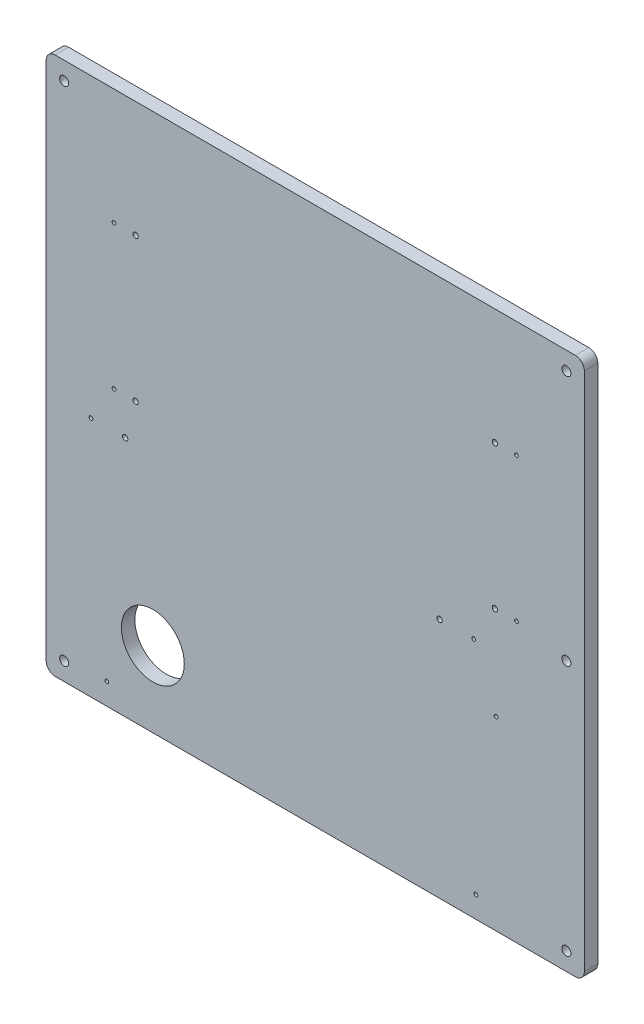
from build123d import *

# Parameters (mm, degrees)
SKETCH1_W           = 599
SKETCH1_H           = 599
BOSS_EXTRUDE1_DEPTH = 15
SKETCH2_R           = 5
CUT_EXTRUDE1_DEPTH  = 16
FILLET1_R           = 10
SKETCH3_R           = 35
CUT_EXTRUDE2_DEPTH  = 16
SKETCH4_R           = 3
CUT_EXTRUDE3_DEPTH  = 16
SKETCH5_R           = 2.1
CUT_EXTRUDE4_DEPTH  = 16


with BuildPart() as part:
    # Sketch1 → Boss-Extrude1 (new body)
    with BuildSketch(Plane.XY):
        Rectangle(SKETCH1_W, SKETCH1_H)
    extrude(amount=BOSS_EXTRUDE1_DEPTH)

    # Sketch2 → Cut-Extrude1 (cut, through all)
    with BuildSketch(Plane.XY.offset(15)):
        with Locations((-279.5, -279.5)):
            Circle(SKETCH2_R)
        with Locations((279.5, -279.5)):
            Circle(SKETCH2_R)
        with Locations((-279.5, 279.5)):
            Circle(SKETCH2_R)
        with Locations((279.5, 279.5)):
            Circle(SKETCH2_R)
        with Locations((279.5, 0)):
            Circle(SKETCH2_R)
    extrude(amount=-CUT_EXTRUDE1_DEPTH, mode=Mode.SUBTRACT)

    # Fillet1
    fillet1_edges = [part.edges().sort_by_distance(p)[0] for p in [
        (-299.5, -299.5, 7.5),
        (299.5, -299.5, 7.5),
        (-299.5, 299.5, 7.5),
        (299.5, 299.5, 7.5),
    ]]
    fillet(fillet1_edges, radius=FILLET1_R)

    # Sketch3 → Cut-Extrude2 (cut, through all)
    with BuildSketch(Plane.XY.offset(15)):
        with Locations((-180.79, -215.5)):
            Circle(SKETCH3_R)
    extrude(amount=-CUT_EXTRUDE2_DEPTH, mode=Mode.SUBTRACT)

    # Sketch4 → Cut-Extrude3 (cut, through all)
    with BuildSketch(Plane.XY.offset(15)):
        with Locations((-200, 170.5)):
            Circle(SKETCH4_R)
        with Locations((-200, 10.5)):
            Circle(SKETCH4_R)
        with Locations((200, 170.5)):
            Circle(SKETCH4_R)
        with Locations((200, 10.5)):
            Circle(SKETCH4_R)
        with Locations((138.4, -30.5)):
            Circle(SKETCH4_R)
        with Locations((-211.6, -30.5)):
            Circle(SKETCH4_R)
    extrude(amount=-CUT_EXTRUDE3_DEPTH, mode=Mode.SUBTRACT)

    # Sketch5 → Cut-Extrude4 (cut, through all)
    with BuildSketch(Plane.XY.offset(15)):
        with Locations((-224, 170.5)):
            Circle(SKETCH5_R)
        with Locations((224, 170.5)):
            Circle(SKETCH5_R)
        with Locations((224, 10.5)):
            Circle(SKETCH5_R)
        with Locations((201.236161147, -92.982459034)):
            Circle(SKETCH5_R)
        with Locations((178.85, -275.5)):
            Circle(SKETCH5_R)
        with Locations((-231.95, -275.5)):
            Circle(SKETCH5_R)
        with Locations((-249.6, -30.5)):
            Circle(SKETCH5_R)
        with Locations((-224, 10.5)):
            Circle(SKETCH5_R)
        with Locations((176.4, -30.5)):
            Circle(SKETCH5_R)
    extrude(amount=-CUT_EXTRUDE4_DEPTH, mode=Mode.SUBTRACT)


solid = part.part
